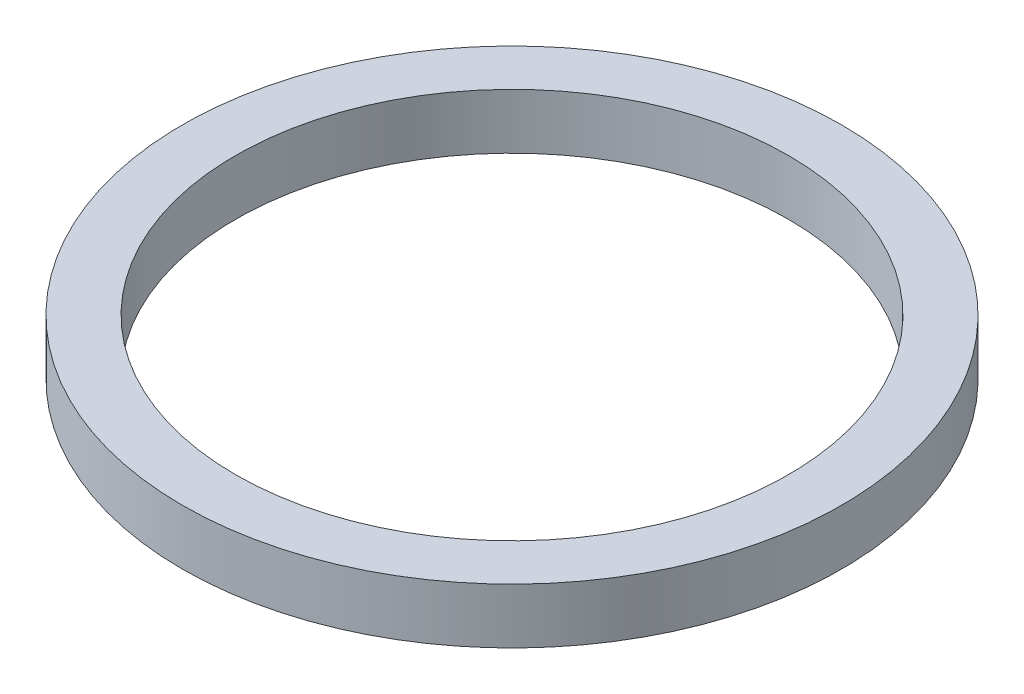
from build123d import *

# Parameters (mm, degrees)
SKETCH1_R           = 9.4615
SKETCH1_R_2         = 7.9375
BOSS_EXTRUDE1_DEPTH = 1.5875


with BuildPart() as part:
    # Sketch1 → Boss-Extrude1 (new body)
    with BuildSketch(Plane(origin=(0, 0, 0), x_dir=(1, 0, 0), z_dir=(0, 1, 0))):
        Circle(SKETCH1_R)
        Circle(SKETCH1_R_2, mode=Mode.SUBTRACT)
    extrude(amount=BOSS_EXTRUDE1_DEPTH)


solid = part.part
